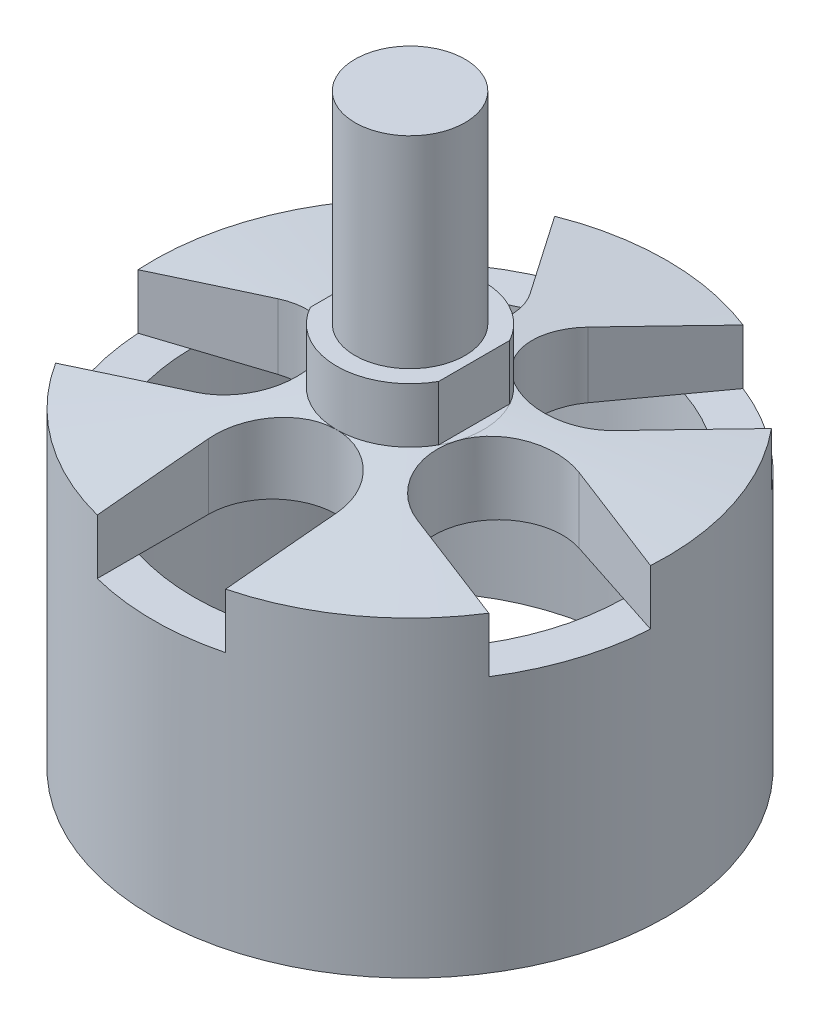
from build123d import *

# Parameters (mm, degrees)
SKETCH_1_R               = 14
SKETCH_1_R_2             = 11.8
EXTRUDE_1_DEPTH          = 14
SKETCH_2_R               = 14
EXTRUDE_2_DEPTH          = 4
CHAMFER_1_SIZE           = 1
CHAMFER_1_SIZE2          = 10
SKETCH_3_R               = 4
EXTRUDE_3_DEPTH          = 3
SKETCH_4_R               = 3
EXTRUDE_4_DEPTH          = 11
SKETCH_5_W               = 6.079740031
SKETCH_5_H               = 11.892824797
SKETCH_5_W_2             = 4.533139496
SKETCH_5_H_2             = 13.012776908
CUT_EXTRUDE_1_DEPTH      = 3
CUT_EXTRUDE_2_DEPTH      = 4
PATTERN_CIRCULAR_1_COUNT = 5


with BuildPart() as part:
    # Эскиз1 → Бобышка-Вытянуть1 (new body)
    with BuildSketch(Plane(origin=(0, 0, 0), x_dir=(1, 0, 0), z_dir=(0, 1, 0))):
        Circle(SKETCH_1_R)
        Circle(SKETCH_1_R_2, mode=Mode.SUBTRACT)
    extrude(amount=EXTRUDE_1_DEPTH)

    # Эскиз2 → Бобышка-Вытянуть2 (add)
    with BuildSketch(Plane(origin=(0, 14, 0), x_dir=(1, 0, 0), z_dir=(0, 1, 0))):
        Circle(SKETCH_2_R)
    extrude(amount=EXTRUDE_2_DEPTH)

    # Фаска1
    chamfer_1_edges = [part.edges().sort_by_distance(p)[0] for p in [
        (-14, 18, 0),
    ]]
    chamfer_1_side = [part.faces().sort_by_distance(p)[0] for p in [
        (-14, 9, 0),
    ]]
    chamfer(chamfer_1_edges, length=CHAMFER_1_SIZE, length2=CHAMFER_1_SIZE2, reference=chamfer_1_side[0])

    # Эскиз3 → Бобышка-Вытянуть3 (add)
    with BuildSketch(Plane(origin=(0, 18, 0), x_dir=(1, 0, 0), z_dir=(0, 1, 0))):
        Circle(SKETCH_3_R)
    extrude(amount=EXTRUDE_3_DEPTH)

    # Эскиз4 → Бобышка-Вытянуть4 (add)
    with BuildSketch(Plane(origin=(0, 21, 0), x_dir=(1, 0, 0), z_dir=(0, 1, 0))):
        Circle(SKETCH_4_R)
    extrude(amount=EXTRUDE_4_DEPTH)

    # Эскиз5 → Вырез-Вытянуть1 (cut)
    with BuildSketch(Plane(origin=(0, 21, 0), x_dir=(1, 0, 0), z_dir=(0, 1, 0))):
        with Locations((-6.539870016, -0.426648424)):
            Rectangle(SKETCH_5_W, SKETCH_5_H)
        with Locations((5.766569748, 0.133327632)):
            Rectangle(SKETCH_5_W_2, SKETCH_5_H_2)
    extrude(amount=-CUT_EXTRUDE_1_DEPTH, mode=Mode.SUBTRACT)

    # Эскиз6 → Вырез-Вытянуть2 (cut)
    with BuildSketch(Plane(origin=(0, 18, 0), x_dir=(1, 0, 0), z_dir=(0, 1, 0))):
        with BuildLine():
            Line((-3.5, -7.5), (-3.5, -15.705995079))
            Line((-3.5, -15.705995079), (3.5, -15.705995079))
            Line((3.5, -15.705995079), (3.5, -7.5))
            ThreePointArc((3.5, -7.5), (0, -4), (-3.5, -7.5))
        make_face()
    cut_extrude_2 = extrude(amount=-CUT_EXTRUDE_2_DEPTH, mode=Mode.SUBTRACT)

    # Круговой массив1: Вырез-Вытянуть2 ×5 about axis
    pattern_circular_1_axis = Axis((0, 0, 0), (0, 1, 0))
    for i in range(1, PATTERN_CIRCULAR_1_COUNT):
        add(cut_extrude_2.rotate(pattern_circular_1_axis, i * 360 / PATTERN_CIRCULAR_1_COUNT), mode=Mode.SUBTRACT)


solid = part.part
